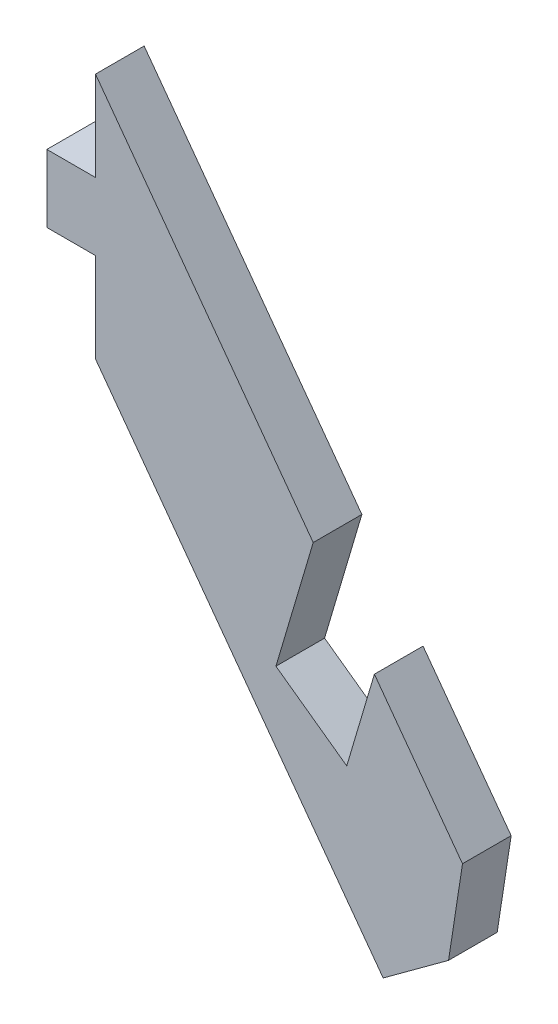
from build123d import *

# Parameters (mm, degrees)
BOSS_EXTRUDE1_DEPTH = 3
SKETCH2_W           = 3
SKETCH2_H           = 4.17
BOSS_EXTRUDE2_DEPTH = 3
CUT_EXTRUDE2_DEPTH  = 3
CHAMFER1_SIZE       = 4


with BuildPart() as part:
    # Sketch1 → Boss-Extrude1 (new body)
    with BuildSketch(Plane.XY):
        Polygon((0, 14.5), (0, -0.717472322), (17.74276268, -24.90826339), (25, -19.585434587), align=None)
    extrude(amount=-BOSS_EXTRUDE1_DEPTH)

    # Sketch2 → Boss-Extrude2 (add)
    with BuildSketch(Plane.XY):
        with Locations((-1.5, 6.891263839)):
            Rectangle(SKETCH2_W, SKETCH2_H)
    extrude(amount=-BOSS_EXTRUDE2_DEPTH)

    # Sketch3 → Cut-Extrude2 (cut)
    with BuildSketch(Plane(origin=(0, 0, -3), x_dir=(-1, 0, 0), z_dir=(0, 0, -1))):
        Polygon((-13.427123713, -3.806773881), (-17.200564762, -8.951549002), (-15.495347423, -14.704133971), (-11.12785759, -11.563394363), align=None)
    extrude(amount=-CUT_EXTRUDE2_DEPTH, mode=Mode.SUBTRACT)

    # Chamfer1
    chamfer1_edges = [part.edges().sort_by_distance(p)[0] for p in [
        (25, -19.585434587, -1.5),
    ]]
    chamfer(chamfer1_edges, length=CHAMFER1_SIZE)


solid = part.part
